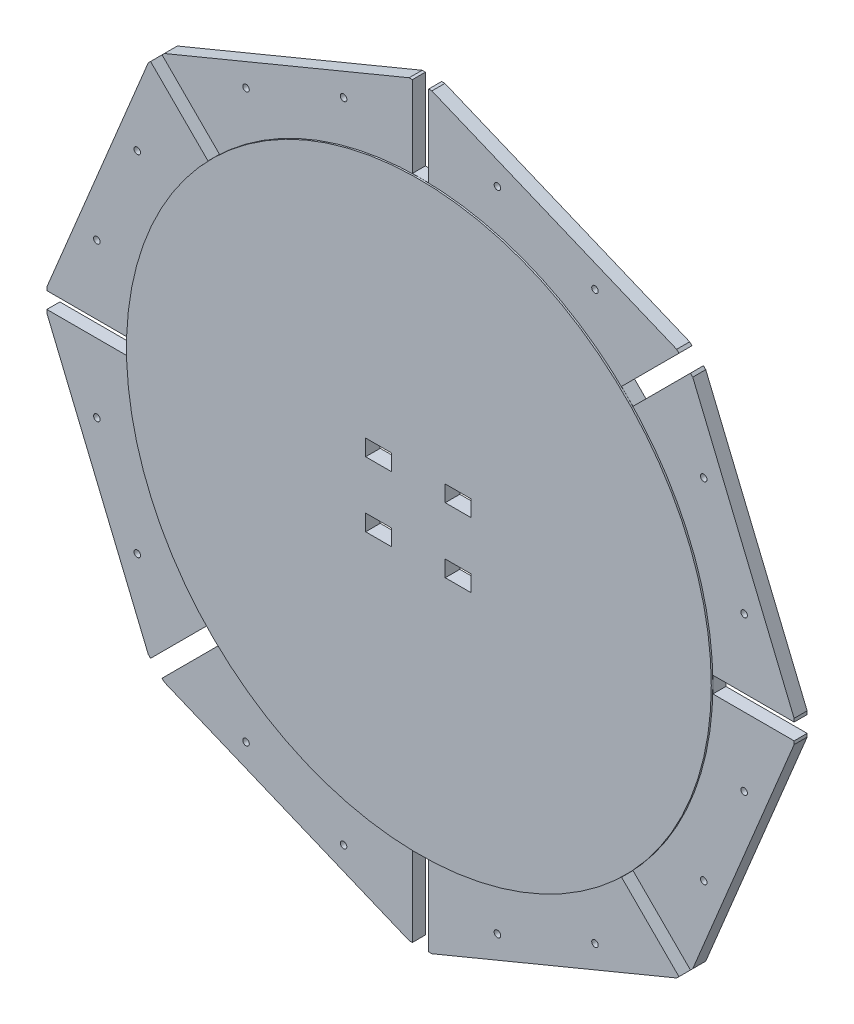
from build123d import *

# Parameters (mm, degrees)
BOSS_EXTRUDE1_DEPTH = 8
SKETCH2_R           = 180
BOSS_EXTRUDE2_DEPTH = 1
CUT_EXTRUDE1_REACH  = 10
SKETCH3_R           = 2
CUT_EXTRUDE2_REACH  = 11
SKETCH5_W           = 16
SKETCH5_H           = 10


with BuildPart() as part:
    # Sketch1 → Boss-Extrude1 (new body)
    with BuildSketch(Plane.XY):
        Polygon((5, 230), (5, 180), (-5, 180), (-5, 230), (-7, 230), (-157.684812205, 167.584307141), (-159.099025767, 166.170093579), (-123.743686708, 130.814754519), (-130.81475452, 123.743686708), (-166.170093579, 159.099025767), (-167.584307141, 157.684812205), (-230, 7), (-230, 5), (-180, 5), (-180, -5), (-230, -5), (-230, -7), (-167.584307141, -157.684812205), (-166.170093579, -159.099025767), (-130.81475452, -123.743686708), (-123.743686708, -130.81475452), (-159.099025767, -166.170093579), (-157.684812205, -167.584307141), (-7, -230), (-5, -230), (-5, -180), (5, -180), (5, -230), (7, -230), (157.684812205, -167.584307141), (159.099025767, -166.170093579), (123.743686708, -130.814754519), (130.81475452, -123.743686708), (166.170093579, -159.099025767), (167.584307141, -157.684812205), (230, -7), (230, -5), (180, -5), (180, 5), (230, 5), (230, 7), (167.584307141, 157.684812205), (166.170093579, 159.099025767), (130.81475452, 123.743686708), (123.743686708, 130.81475452), (159.099025767, 166.170093579), (157.684812205, 167.584307141), (7, 230), align=None)
    extrude(amount=BOSS_EXTRUDE1_DEPTH)

    # Sketch2 → Boss-Extrude2 (add)
    with BuildSketch(Plane.XY.offset(8)):
        Circle(SKETCH2_R)
    extrude(amount=BOSS_EXTRUDE2_DEPTH)

    # Sketch3 → Cut-Extrude1 (cut, up to next)
    with BuildSketch(Plane.XY.offset(8), mode=Mode.PRIVATE) as cut_extrude1_sk1:
        with Locations((107.397750993, 174.354514299)):
            Circle(SKETCH3_R)
    cut_extrude1_tool1 = extrude(cut_extrude1_sk1.sketch, amount=-CUT_EXTRUDE1_REACH, mode=Mode.PRIVATE) & part.part
    add(cut_extrude1_tool1.solids().sort_by_distance((107.397751, 174.354514, 8))[0], mode=Mode.SUBTRACT)
    # Sketch3 → Cut-Extrude1 (cut, up to next)
    with BuildSketch(Plane.XY.offset(8), mode=Mode.PRIVATE) as cut_extrude1_sk2:
        with Locations((47.34558138, 199.228937402)):
            Circle(SKETCH3_R)
    cut_extrude1_tool2 = extrude(cut_extrude1_sk2.sketch, amount=-CUT_EXTRUDE1_REACH, mode=Mode.PRIVATE) & part.part
    add(cut_extrude1_tool2.solids().sort_by_distance((47.345581, 199.228937, 8))[0], mode=Mode.SUBTRACT)
    # Sketch3 → Cut-Extrude1 (cut, up to next)
    with BuildSketch(Plane.XY.offset(8), mode=Mode.PRIVATE) as cut_extrude1_sk3:
        with Locations((199.228937402, 47.34558138)):
            Circle(SKETCH3_R)
    cut_extrude1_tool3 = extrude(cut_extrude1_sk3.sketch, amount=-CUT_EXTRUDE1_REACH, mode=Mode.PRIVATE) & part.part
    add(cut_extrude1_tool3.solids().sort_by_distance((199.228937, 47.345581, 8))[0], mode=Mode.SUBTRACT)
    # Sketch3 → Cut-Extrude1 (cut, up to next)
    with BuildSketch(Plane.XY.offset(8), mode=Mode.PRIVATE) as cut_extrude1_sk4:
        with Locations((174.354514299, 107.397750993)):
            Circle(SKETCH3_R)
    cut_extrude1_tool4 = extrude(cut_extrude1_sk4.sketch, amount=-CUT_EXTRUDE1_REACH, mode=Mode.PRIVATE) & part.part
    add(cut_extrude1_tool4.solids().sort_by_distance((174.354514, 107.397751, 8))[0], mode=Mode.SUBTRACT)
    # Sketch3 → Cut-Extrude1 (cut, up to next)
    with BuildSketch(Plane.XY.offset(8), mode=Mode.PRIVATE) as cut_extrude1_sk5:
        with Locations((174.354514299, -107.397750993)):
            Circle(SKETCH3_R)
    cut_extrude1_tool5 = extrude(cut_extrude1_sk5.sketch, amount=-CUT_EXTRUDE1_REACH, mode=Mode.PRIVATE) & part.part
    add(cut_extrude1_tool5.solids().sort_by_distance((174.354514, -107.397751, 8))[0], mode=Mode.SUBTRACT)
    # Sketch3 → Cut-Extrude1 (cut, up to next)
    with BuildSketch(Plane.XY.offset(8), mode=Mode.PRIVATE) as cut_extrude1_sk6:
        with Locations((199.228937402, -47.34558138)):
            Circle(SKETCH3_R)
    cut_extrude1_tool6 = extrude(cut_extrude1_sk6.sketch, amount=-CUT_EXTRUDE1_REACH, mode=Mode.PRIVATE) & part.part
    add(cut_extrude1_tool6.solids().sort_by_distance((199.228937, -47.345581, 8))[0], mode=Mode.SUBTRACT)
    # Sketch3 → Cut-Extrude1 (cut, up to next)
    with BuildSketch(Plane.XY.offset(8), mode=Mode.PRIVATE) as cut_extrude1_sk7:
        with Locations((47.34558138, -199.228937402)):
            Circle(SKETCH3_R)
    cut_extrude1_tool7 = extrude(cut_extrude1_sk7.sketch, amount=-CUT_EXTRUDE1_REACH, mode=Mode.PRIVATE) & part.part
    add(cut_extrude1_tool7.solids().sort_by_distance((47.345581, -199.228937, 8))[0], mode=Mode.SUBTRACT)
    # Sketch3 → Cut-Extrude1 (cut, up to next)
    with BuildSketch(Plane.XY.offset(8), mode=Mode.PRIVATE) as cut_extrude1_sk8:
        with Locations((107.397750993, -174.354514299)):
            Circle(SKETCH3_R)
    cut_extrude1_tool8 = extrude(cut_extrude1_sk8.sketch, amount=-CUT_EXTRUDE1_REACH, mode=Mode.PRIVATE) & part.part
    add(cut_extrude1_tool8.solids().sort_by_distance((107.397751, -174.354514, 8))[0], mode=Mode.SUBTRACT)
    # Sketch3 → Cut-Extrude1 (cut, up to next)
    with BuildSketch(Plane.XY.offset(8), mode=Mode.PRIVATE) as cut_extrude1_sk9:
        with Locations((-107.397750993, -174.354514299)):
            Circle(SKETCH3_R)
    cut_extrude1_tool9 = extrude(cut_extrude1_sk9.sketch, amount=-CUT_EXTRUDE1_REACH, mode=Mode.PRIVATE) & part.part
    add(cut_extrude1_tool9.solids().sort_by_distance((-107.397751, -174.354514, 8))[0], mode=Mode.SUBTRACT)
    # Sketch3 → Cut-Extrude1 (cut, up to next)
    with BuildSketch(Plane.XY.offset(8), mode=Mode.PRIVATE) as cut_extrude1_sk10:
        with Locations((-47.34558138, -199.228937402)):
            Circle(SKETCH3_R)
    cut_extrude1_tool10 = extrude(cut_extrude1_sk10.sketch, amount=-CUT_EXTRUDE1_REACH, mode=Mode.PRIVATE) & part.part
    add(cut_extrude1_tool10.solids().sort_by_distance((-47.345581, -199.228937, 8))[0], mode=Mode.SUBTRACT)
    # Sketch3 → Cut-Extrude1 (cut, up to next)
    with BuildSketch(Plane.XY.offset(8), mode=Mode.PRIVATE) as cut_extrude1_sk11:
        with Locations((-199.228937402, -47.34558138)):
            Circle(SKETCH3_R)
    cut_extrude1_tool11 = extrude(cut_extrude1_sk11.sketch, amount=-CUT_EXTRUDE1_REACH, mode=Mode.PRIVATE) & part.part
    add(cut_extrude1_tool11.solids().sort_by_distance((-199.228937, -47.345581, 8))[0], mode=Mode.SUBTRACT)
    # Sketch3 → Cut-Extrude1 (cut, up to next)
    with BuildSketch(Plane.XY.offset(8), mode=Mode.PRIVATE) as cut_extrude1_sk12:
        with Locations((-174.354514299, -107.397750993)):
            Circle(SKETCH3_R)
    cut_extrude1_tool12 = extrude(cut_extrude1_sk12.sketch, amount=-CUT_EXTRUDE1_REACH, mode=Mode.PRIVATE) & part.part
    add(cut_extrude1_tool12.solids().sort_by_distance((-174.354514, -107.397751, 8))[0], mode=Mode.SUBTRACT)
    # Sketch3 → Cut-Extrude1 (cut, up to next)
    with BuildSketch(Plane.XY.offset(8), mode=Mode.PRIVATE) as cut_extrude1_sk13:
        with Locations((-174.354514299, 107.397750993)):
            Circle(SKETCH3_R)
    cut_extrude1_tool13 = extrude(cut_extrude1_sk13.sketch, amount=-CUT_EXTRUDE1_REACH, mode=Mode.PRIVATE) & part.part
    add(cut_extrude1_tool13.solids().sort_by_distance((-174.354514, 107.397751, 8))[0], mode=Mode.SUBTRACT)
    # Sketch3 → Cut-Extrude1 (cut, up to next)
    with BuildSketch(Plane.XY.offset(8), mode=Mode.PRIVATE) as cut_extrude1_sk14:
        with Locations((-199.228937402, 47.34558138)):
            Circle(SKETCH3_R)
    cut_extrude1_tool14 = extrude(cut_extrude1_sk14.sketch, amount=-CUT_EXTRUDE1_REACH, mode=Mode.PRIVATE) & part.part
    add(cut_extrude1_tool14.solids().sort_by_distance((-199.228937, 47.345581, 8))[0], mode=Mode.SUBTRACT)
    # Sketch3 → Cut-Extrude1 (cut, up to next)
    with BuildSketch(Plane.XY.offset(8), mode=Mode.PRIVATE) as cut_extrude1_sk15:
        with Locations((-47.34558138, 199.228937402)):
            Circle(SKETCH3_R)
    cut_extrude1_tool15 = extrude(cut_extrude1_sk15.sketch, amount=-CUT_EXTRUDE1_REACH, mode=Mode.PRIVATE) & part.part
    add(cut_extrude1_tool15.solids().sort_by_distance((-47.345581, 199.228937, 8))[0], mode=Mode.SUBTRACT)
    # Sketch3 → Cut-Extrude1 (cut, up to next)
    with BuildSketch(Plane.XY.offset(8), mode=Mode.PRIVATE) as cut_extrude1_sk16:
        with Locations((-107.397750993, 174.354514299)):
            Circle(SKETCH3_R)
    cut_extrude1_tool16 = extrude(cut_extrude1_sk16.sketch, amount=-CUT_EXTRUDE1_REACH, mode=Mode.PRIVATE) & part.part
    add(cut_extrude1_tool16.solids().sort_by_distance((-107.397751, 174.354514, 8))[0], mode=Mode.SUBTRACT)

    # Sketch5 → Cut-Extrude2 (cut, up to next)
    with BuildSketch(Plane(origin=(0, 0, 0), x_dir=(-1, 0, 0), z_dir=(0, 0, -1)), mode=Mode.PRIVATE) as cut_extrude2_sk1:
        with Locations((-24.221028692, -19.442057383)):
            Rectangle(SKETCH5_W, SKETCH5_H)
    cut_extrude2_tool1 = extrude(cut_extrude2_sk1.sketch, amount=-CUT_EXTRUDE2_REACH, mode=Mode.PRIVATE) & part.part
    add(cut_extrude2_tool1.solids().sort_by_distance((24.221029, -19.442057, 0))[0], mode=Mode.SUBTRACT)
    # Sketch5 → Cut-Extrude2 (cut, up to next)
    with BuildSketch(Plane(origin=(0, 0, 0), x_dir=(-1, 0, 0), z_dir=(0, 0, -1)), mode=Mode.PRIVATE) as cut_extrude2_sk2:
        with Locations((-24.221028692, 20.557942617)):
            Rectangle(SKETCH5_W, SKETCH5_H)
    cut_extrude2_tool2 = extrude(cut_extrude2_sk2.sketch, amount=-CUT_EXTRUDE2_REACH, mode=Mode.PRIVATE) & part.part
    add(cut_extrude2_tool2.solids().sort_by_distance((24.221029, 20.557943, 0))[0], mode=Mode.SUBTRACT)
    # Sketch5 → Cut-Extrude2 (cut, up to next)
    with BuildSketch(Plane(origin=(0, 0, 0), x_dir=(-1, 0, 0), z_dir=(0, 0, -1)), mode=Mode.PRIVATE) as cut_extrude2_sk3:
        with Locations((24.778971308, 20.557942617)):
            Rectangle(SKETCH5_W, SKETCH5_H)
    cut_extrude2_tool3 = extrude(cut_extrude2_sk3.sketch, amount=-CUT_EXTRUDE2_REACH, mode=Mode.PRIVATE) & part.part
    add(cut_extrude2_tool3.solids().sort_by_distance((-24.778971, 20.557943, 0))[0], mode=Mode.SUBTRACT)
    # Sketch5 → Cut-Extrude2 (cut, up to next)
    with BuildSketch(Plane(origin=(0, 0, 0), x_dir=(-1, 0, 0), z_dir=(0, 0, -1)), mode=Mode.PRIVATE) as cut_extrude2_sk4:
        with Locations((24.778971308, -19.442057383)):
            Rectangle(SKETCH5_W, SKETCH5_H)
    cut_extrude2_tool4 = extrude(cut_extrude2_sk4.sketch, amount=-CUT_EXTRUDE2_REACH, mode=Mode.PRIVATE) & part.part
    add(cut_extrude2_tool4.solids().sort_by_distance((-24.778971, -19.442057, 0))[0], mode=Mode.SUBTRACT)


solid = part.part
